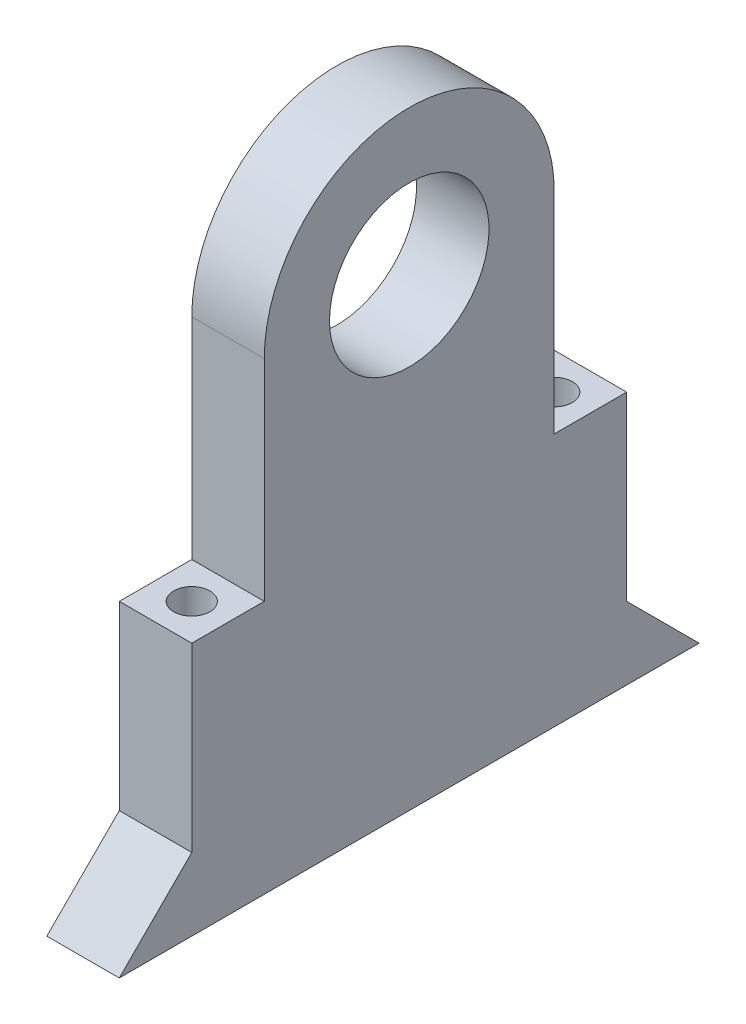
from build123d import *

# Parameters (mm, degrees)
BOSS_EXTRUDE1_DEPTH            = 5
F_11_0_11_DIAMETER_HOLE1_D     = 11
F_11_0_11_DIAMETER_HOLE1_DEPTH = 25
F_11_0_11_DIAMETER_HOLE1_TIP   = 3.304733405
M3_TAPPED_HOLE3_D              = 2.5
M3_TAPPED_HOLE3_DEPTH          = 8
M3_TAPPED_HOLE3_TIP            = 0.751075774


with BuildPart() as part:
    # Sketch1 → Boss-Extrude1 (new body)
    with BuildSketch(Plane(origin=(0, 0, 0), x_dir=(0, 0, -1), z_dir=(1, 0, 0))):
        with BuildLine():
            Line((10, 0), (-10, 0))
            Line((-10, 0), (-20, 0))
            Line((-20, 0), (-15, 5))
            Line((-15, 5), (-15, 10))
            Line((-15, 10), (-15, 17.5))
            Line((-15, 17.5), (-10, 17.5))
            Line((-10, 17.5), (-10, 32))
            ThreePointArc((-10, 32), (0, 42), (10, 32))
            Line((10, 32), (10, 17.5))
            Line((10, 17.5), (15, 17.5))
            Line((15, 17.5), (15, 10))
            Line((15, 10), (15, 5))
            Line((15, 5), (20, 0))
            Line((20, 0), (10, 0))
        make_face()
    extrude(amount=BOSS_EXTRUDE1_DEPTH)

    # Ø11.0 (11) Diameter Hole1
    with Locations(Plane(origin=(0, 32, 0), x_dir=(0, 0, -1), z_dir=(-1, 0, 0))):
        with Locations((0, 0)):
            Hole(F_11_0_11_DIAMETER_HOLE1_D / 2, depth=F_11_0_11_DIAMETER_HOLE1_DEPTH)
            with Locations((0, 0, -(F_11_0_11_DIAMETER_HOLE1_DEPTH + F_11_0_11_DIAMETER_HOLE1_TIP / 2))):  # 118° drill point
                Cone(0, F_11_0_11_DIAMETER_HOLE1_D / 2, F_11_0_11_DIAMETER_HOLE1_TIP, mode=Mode.SUBTRACT)

    # Sketch9 → M3 Tapped Hole2 (revolve, cut)
    with BuildSketch(Plane(origin=(2.5, 17.5, -12.5), x_dir=(0, 0, 1), z_dir=(1, 0, 0))):
        Polygon((0, 0), (0, 18.751075774), (1.25, 18), (1.25, 0), align=None)
    m3_tapped_hole2 = revolve(axis=Axis((2.5, 23.85, -12.5), (0, -1, 0)), mode=Mode.SUBTRACT)

    # Mirror1: M3 Tapped Hole2 across plane
    add(m3_tapped_hole2.mirror(Plane.XY), mode=Mode.SUBTRACT)

    # M3 Tapped Hole3
    with Locations(Plane(origin=(2.5, 0, 8), x_dir=(0, 0, -1), z_dir=(0, -1, 0))):
        with Locations((0, 0), (8, 0), (16, 0)):
            Hole(M3_TAPPED_HOLE3_D / 2, depth=M3_TAPPED_HOLE3_DEPTH)
            with Locations((0, 0, -(M3_TAPPED_HOLE3_DEPTH + M3_TAPPED_HOLE3_TIP / 2))):  # 118° drill point
                Cone(0, M3_TAPPED_HOLE3_D / 2, M3_TAPPED_HOLE3_TIP, mode=Mode.SUBTRACT)


solid = part.part
